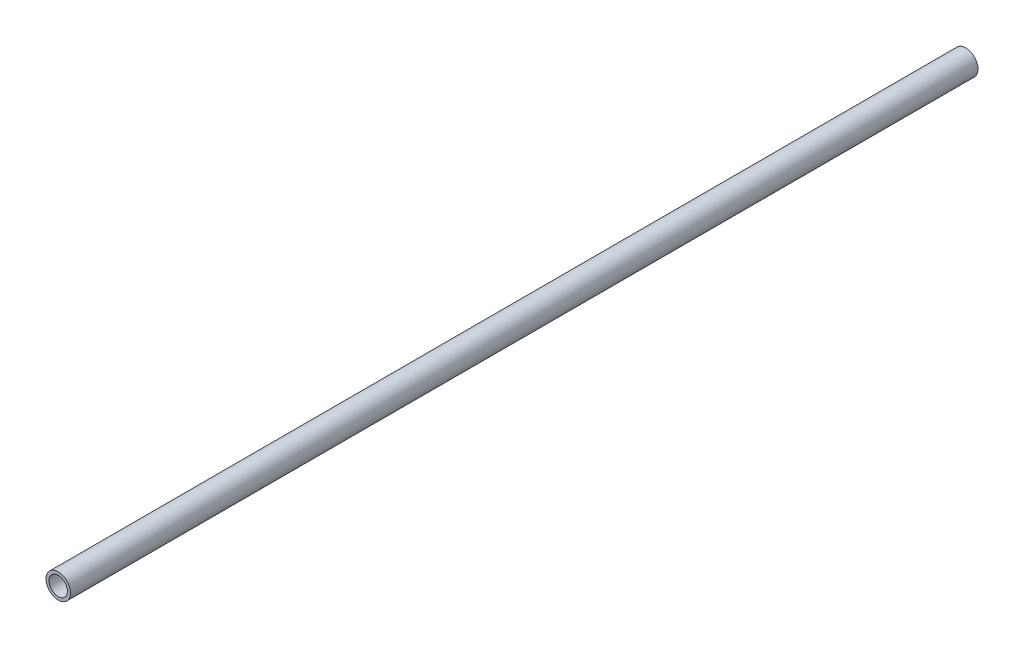
from build123d import *

# Parameters (mm, degrees)
SKETCH1_R           = 12.7
SKETCH1_R_2         = 9.525
BOSS_EXTRUDE1_DEPTH = 939.8


with BuildPart() as part:
    # Sketch1 → Boss-Extrude1 (new body)
    with BuildSketch(Plane.XY):
        Circle(SKETCH1_R)
        Circle(SKETCH1_R_2, mode=Mode.SUBTRACT)
    extrude(amount=BOSS_EXTRUDE1_DEPTH)


solid = part.part
